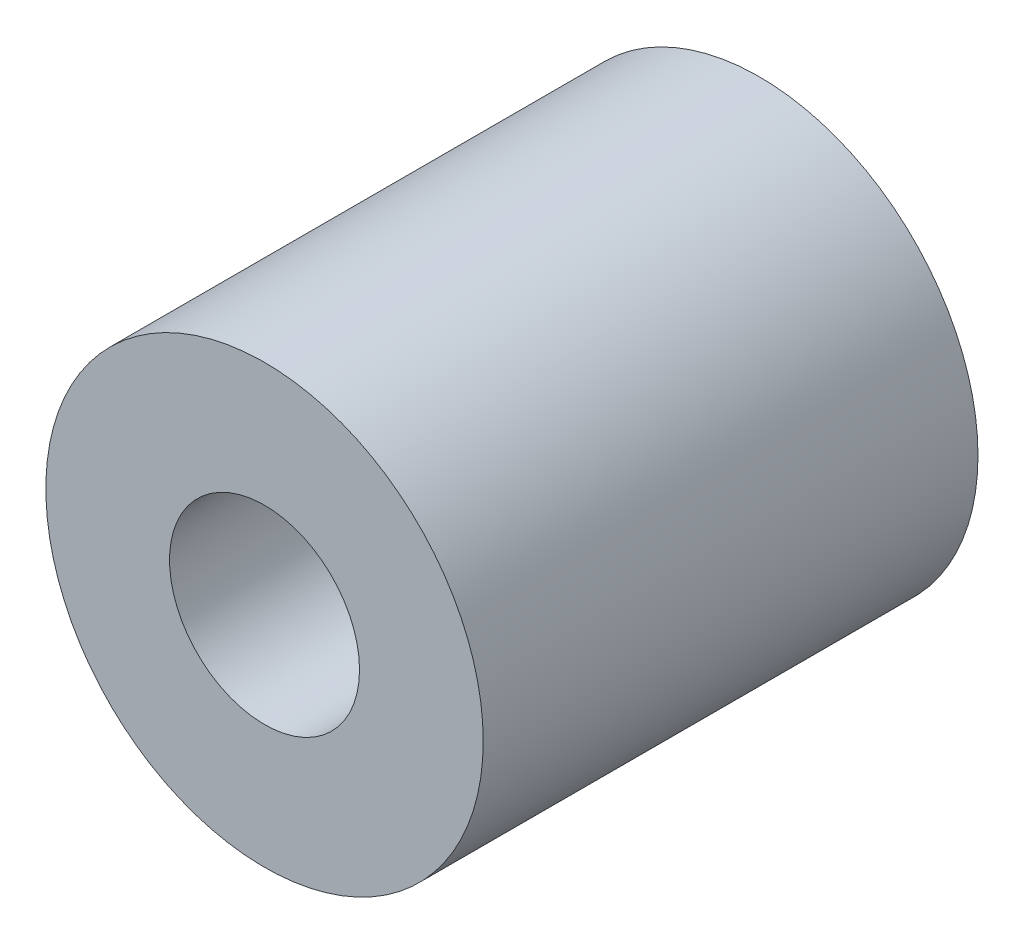
from build123d import *

# Parameters (mm, degrees)
SKETCH1_R           = 5.6134
SKETCH1_R_2         = 2.4384
BOSS_EXTRUDE1_DEPTH = 12.7


with BuildPart() as part:
    # Sketch1 → Boss-Extrude1 (new body)
    with BuildSketch(Plane.XY):
        Circle(SKETCH1_R)
        Circle(SKETCH1_R_2, mode=Mode.SUBTRACT)
    extrude(amount=BOSS_EXTRUDE1_DEPTH)


solid = part.part
